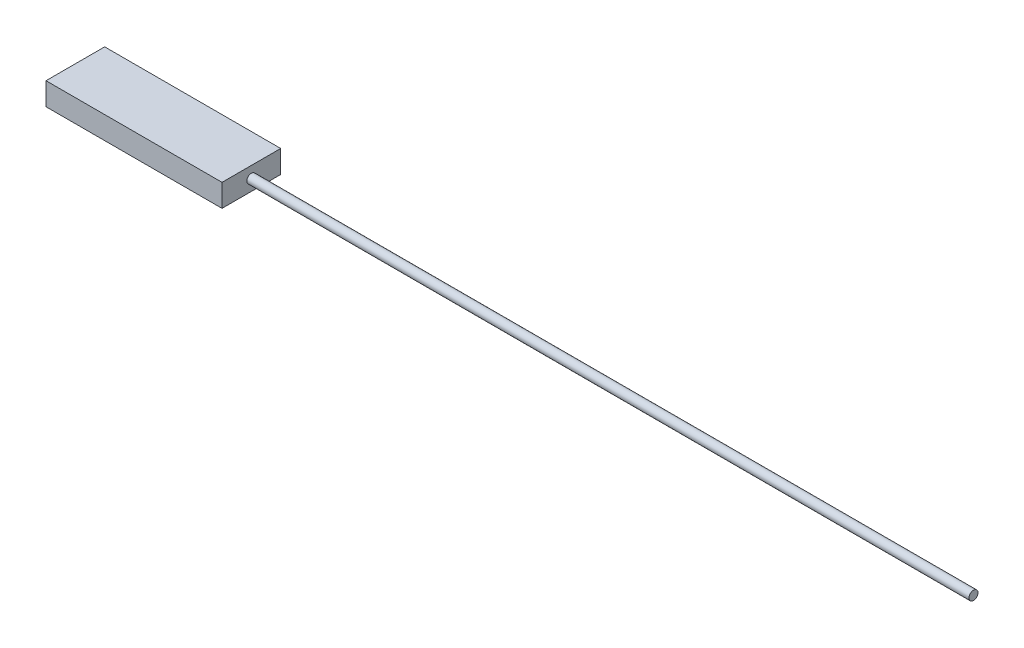
from build123d import *

# Parameters (mm, degrees)
SKETCH1_W           = 99.06
SKETCH1_H           = 33.02
BOSS_EXTRUDE1_DEPTH = 12.7
SKETCH2_R           = 2.54
BOSS_EXTRUDE2_DEPTH = 406.4


with BuildPart() as part:
    # Sketch1 → Boss-Extrude1 (new body)
    with BuildSketch(Plane(origin=(0, 0, 0), x_dir=(1, 0, 0), z_dir=(0, 1, 0))):
        Rectangle(SKETCH1_W, SKETCH1_H)
    extrude(amount=BOSS_EXTRUDE1_DEPTH)

    # Sketch2 → Boss-Extrude2 (add)
    with BuildSketch(Plane(origin=(49.53, 0, 0), x_dir=(0, 0, -1), z_dir=(1, 0, 0))):
        with Locations((0, 6.35)):
            Circle(SKETCH2_R)
    extrude(amount=BOSS_EXTRUDE2_DEPTH)


solid = part.part
